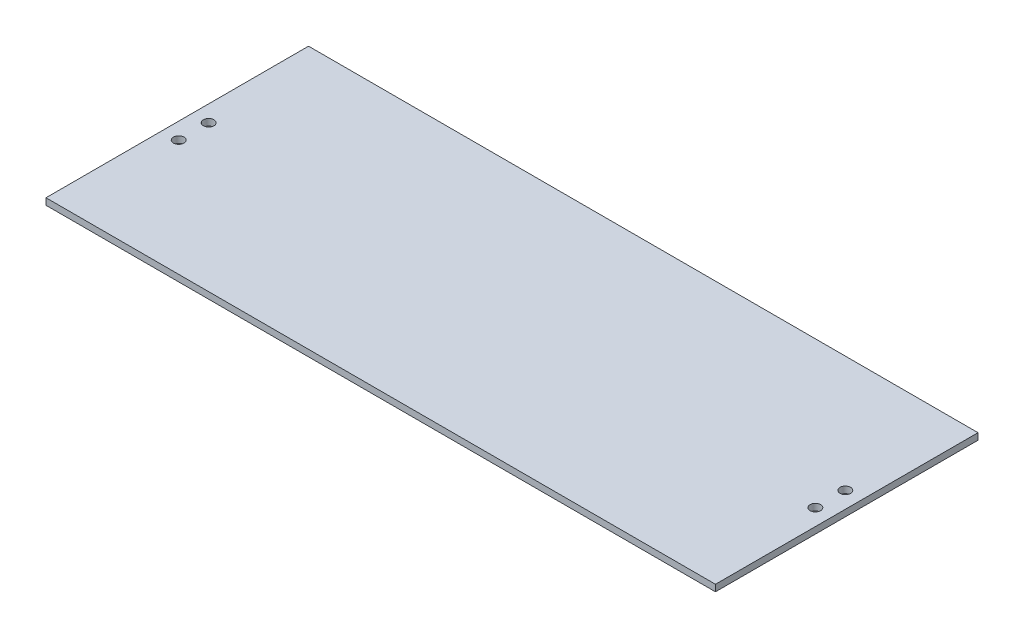
from build123d import *

# Parameters (mm, degrees)
SKETCH1_W              = 323.85
SKETCH1_H              = 127
BOSS_EXTRUDE1_DEPTH    = 3.175
F_10_CLEARANCE_HOLE1_D = 5.1054


with BuildPart() as part:
    # Sketch1 → Boss-Extrude1 (new body)
    with BuildSketch(Plane(origin=(0, 0, 0), x_dir=(1, 0, 0), z_dir=(0, 1, 0))):
        with Locations((161.925, 63.5)):
            Rectangle(SKETCH1_W, SKETCH1_H)
    extrude(amount=BOSS_EXTRUDE1_DEPTH)

    # #10 Clearance Hole1 (through all)
    with Locations(Plane(origin=(0, 0, 0), x_dir=(-1, 0, 0), z_dir=(0, -1, 0))):
        with Locations((-315.9125, 56.25), (-315.9125, 70.75), (-7.9375, 70.75), (-7.9375, 56.25)):
            Hole(F_10_CLEARANCE_HOLE1_D / 2)


solid = part.part
